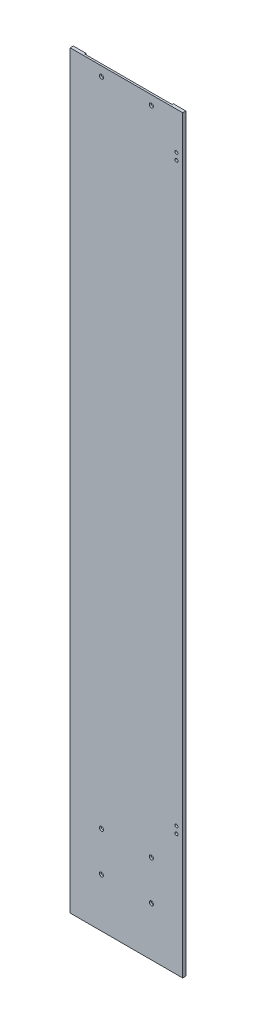
from build123d import *

# Parameters (mm, degrees)
SKETCH1_W           = 180
SKETCH1_H           = 1200
BOSS_EXTRUDE1_DEPTH = 5
SKETCH2_W           = 140
SKETCH2_H           = 1200
CUT_EXTRUDE1_DEPTH  = 2
SKETCH3_R           = 3.3
CUT_EXTRUDE2_DEPTH  = 6
SKETCH4_R           = 2.5
CUT_EXTRUDE3_DEPTH  = 6


with BuildPart() as part:
    # Sketch1 → Boss-Extrude1 (new body)
    with BuildSketch(Plane.XY):
        Rectangle(SKETCH1_W, SKETCH1_H)
    extrude(amount=BOSS_EXTRUDE1_DEPTH)

    # Sketch2 → Cut-Extrude1 (cut)
    with BuildSketch(Plane(origin=(0, 0, 0), x_dir=(-1, 0, 0), z_dir=(0, 0, -1))):
        Rectangle(SKETCH2_W, SKETCH2_H)
    extrude(amount=-CUT_EXTRUDE1_DEPTH, mode=Mode.SUBTRACT)

    # Sketch3 → Cut-Extrude2 (cut, through all)
    with BuildSketch(Plane.XY.offset(5)):
        with Locations((-40, -521.5)):
            Circle(SKETCH3_R)
        with Locations((-40, -458)):
            Circle(SKETCH3_R)
        with Locations((-40, 585)):
            Circle(SKETCH3_R)
        with Locations((40, 585)):
            Circle(SKETCH3_R)
        with Locations((40, -458)):
            Circle(SKETCH3_R)
        with Locations((40, -521.5)):
            Circle(SKETCH3_R)
    extrude(amount=-CUT_EXTRUDE2_DEPTH, mode=Mode.SUBTRACT)

    # Sketch4 → Cut-Extrude3 (cut, through all)
    with BuildSketch(Plane(origin=(0, 0, 0), x_dir=(-1, 0, 0), z_dir=(0, 0, -1))):
        with Locations((-80, 539.95)):
            Circle(SKETCH4_R)
        with Locations((-80, 529)):
            Circle(SKETCH4_R)
        with Locations((-80, -394.05)):
            Circle(SKETCH4_R)
        with Locations((-80, -405)):
            Circle(SKETCH4_R)
    extrude(amount=-CUT_EXTRUDE3_DEPTH, mode=Mode.SUBTRACT)


solid = part.part
